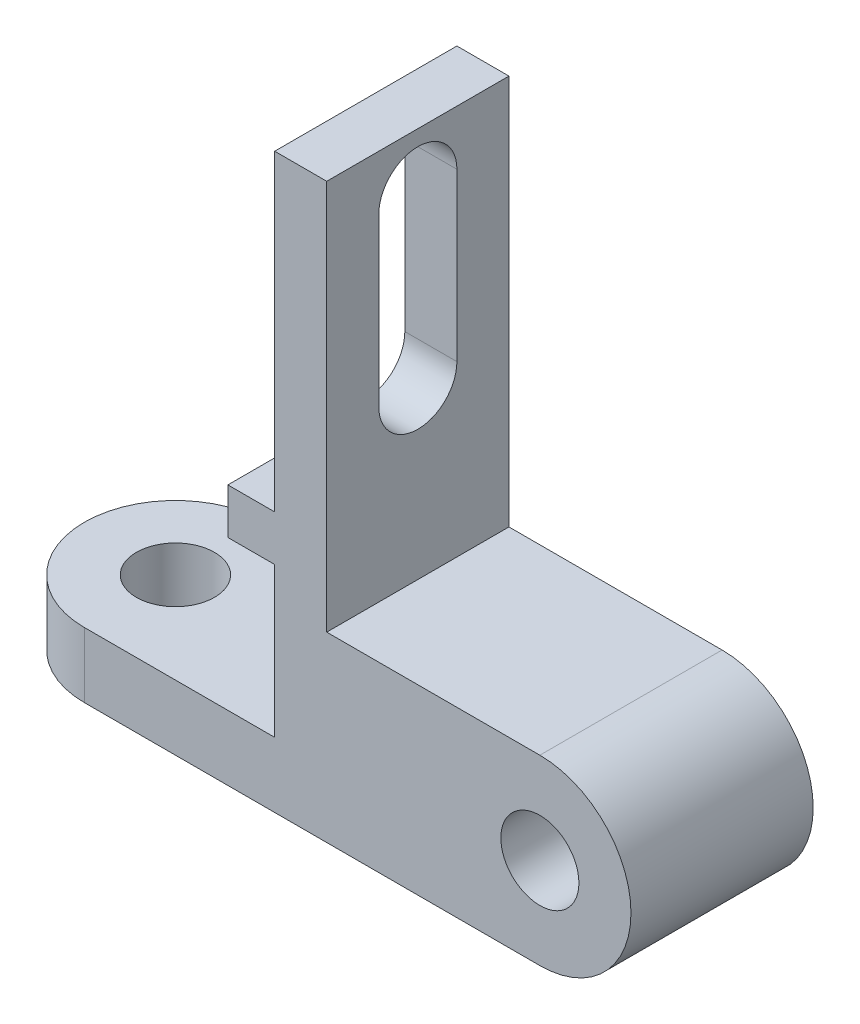
from build123d import *

# Parameters (mm, degrees)
SKETCH1_R           = 6
BOSS_EXTRUDE1_DEPTH = 14
BOSS_EXTRUDE3_DEPTH = 10
SKETCH4_R           = 6
CUT_EXTRUDE1_DEPTH  = 10
CUT_EXTRUDE2_DEPTH  = 10


with BuildPart() as part:
    # Sketch1 → Boss-Extrude1 (new body, symmetric)
    with BuildSketch(Plane.XY):
        with BuildLine():
            Line((0, -14), (-70, -14))
            Line((-70, -14), (-70, -4))
            Line((-70, -4), (-40.749302813, -4))
            Line((-40.749302813, -4), (-40.749302813, 19))
            Line((-40.749302813, 19), (-47.94035625, 19))
            Line((-47.94035625, 19), (-47.94035625, 26))
            Line((-47.94035625, 26), (-40.749302813, 26))
            Line((-40.749302813, 26), (-40.749302813, 74))
            Line((-40.749302813, 74), (-32.749302813, 74))
            Line((-32.749302813, 74), (-32.749302813, 14))
            Line((-32.749302813, 14), (0, 14))
            ThreePointArc((0, 14), (14, 0), (0, -14))
        make_face()
        Circle(SKETCH1_R, mode=Mode.SUBTRACT)
    extrude(amount=BOSS_EXTRUDE1_DEPTH, both=True)

    # Sketch3 → Boss-Extrude3 (add)
    with BuildSketch(Plane(origin=(0, -4, 0), x_dir=(1, 0, 0), z_dir=(0, 1, 0))):
        with BuildLine():
            Line((-70, -14), (-70, 14))
            ThreePointArc((-70, 14), (-84, 0), (-70, -14))
        make_face()
    extrude(amount=-BOSS_EXTRUDE3_DEPTH)

    # Sketch4 → Cut-Extrude1 (cut)
    with BuildSketch(Plane(origin=(0, -4, 0), x_dir=(1, 0, 0), z_dir=(0, 1, 0))):
        with Locations((-70, 0)):
            Circle(SKETCH4_R)
    extrude(amount=-CUT_EXTRUDE1_DEPTH, mode=Mode.SUBTRACT)

    # Sketch5 → Cut-Extrude2 (cut)
    with BuildSketch(Plane(origin=(-32.749302813, 0, 0), x_dir=(0, 0, -1), z_dir=(1, 0, 0))):
        with BuildLine():
            Line((-6, 65.598278873), (-6, 40))
            ThreePointArc((-6, 40), (0, 34), (6, 40))
            Line((6, 40), (6, 65.598278873))
            ThreePointArc((6, 65.598278873), (0, 71.598278873), (-6, 65.598278873))
        make_face()
    extrude(amount=-CUT_EXTRUDE2_DEPTH, mode=Mode.SUBTRACT)


solid = part.part
